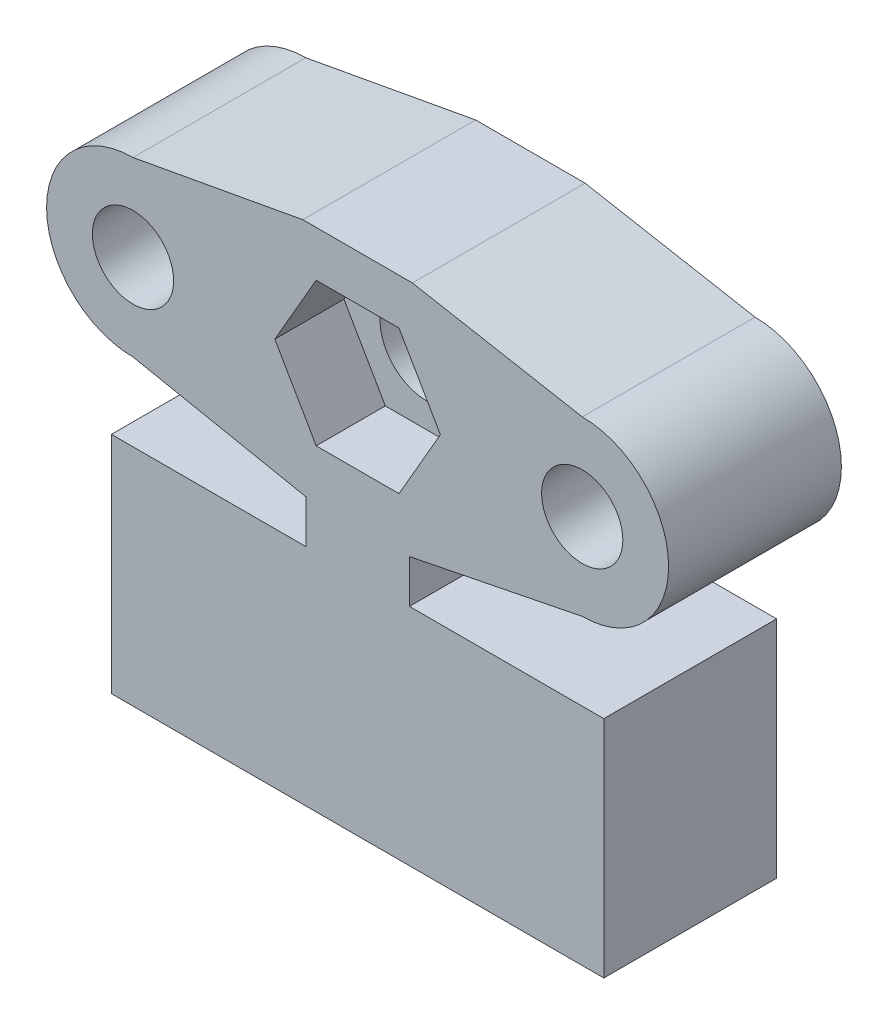
from build123d import *

# Parameters (mm, degrees)
ESQUISSE1_R            = 2.35
FORME_PRINCIPALE_DEPTH = 10
ESQUISSE1_5_R          = 2.7
ECROU_DEPTH            = 6
ESQUISSE3_R            = 0.85
VIS_DEPTH              = 8


with BuildPart() as part:
    # Esquisse1 → forme principale (new body)
    with BuildSketch(Plane.XY):
        with BuildLine():
            Line((-14.25, 6.5), (-14.25, -6.5))
            Line((-14.25, -6.5), (14.25, -6.5))
            Line((14.25, -6.5), (14.25, 6.5))
            Line((14.25, 6.5), (3, 6.5))
            Line((3, 6.5), (3, 9))
            Line((3, 9), (13, 11))
            ThreePointArc((13, 11), (18, 16), (13, 21))
            Line((13, 21), (3.169636963, 22.797308403))
            Line((3.169636963, 22.797308403), (-3.169636963, 22.797308403))
            Line((-3.169636963, 22.797308403), (-13, 21))
            ThreePointArc((-13, 21), (-18, 16), (-13, 11))
            Line((-13, 11), (-3, 9))
            Line((-3, 9), (-3, 6.5))
            Line((-3, 6.5), (-14.25, 6.5))
        make_face()
        with Locations((-13, 16)):
            Circle(ESQUISSE1_R, mode=Mode.SUBTRACT)
        Polygon((4.792007234, 16), (2.396003617, 11.85), (-2.396003617, 11.85), (-4.792007234, 16), (-2.396003617, 20.15), (2.396003617, 20.15), align=None, mode=Mode.SUBTRACT)
        with Locations((13, 16)):
            Circle(ESQUISSE1_R, mode=Mode.SUBTRACT)
    extrude(amount=FORME_PRINCIPALE_DEPTH)

    # Esquisse1_5 → ecrou (add)
    with BuildSketch(Plane.XY):
        Polygon((-2.396003617, 11.85), (2.396003617, 11.85), (4.792007234, 16), (2.396003617, 20.15), (-2.396003617, 20.15), (-4.792007234, 16), align=None)
        with Locations((0, 16)):
            Circle(ESQUISSE1_5_R, mode=Mode.SUBTRACT)
    extrude(amount=ECROU_DEPTH)

    # Esquisse3 → vis (cut)
    with BuildSketch(Plane.XZ.offset(6.5)):
        with Locations((-9.25, 3)):
            Circle(ESQUISSE3_R)
        with Locations((0.45, 3)):
            Circle(ESQUISSE3_R)
    extrude(amount=-VIS_DEPTH, mode=Mode.SUBTRACT)


solid = part.part
